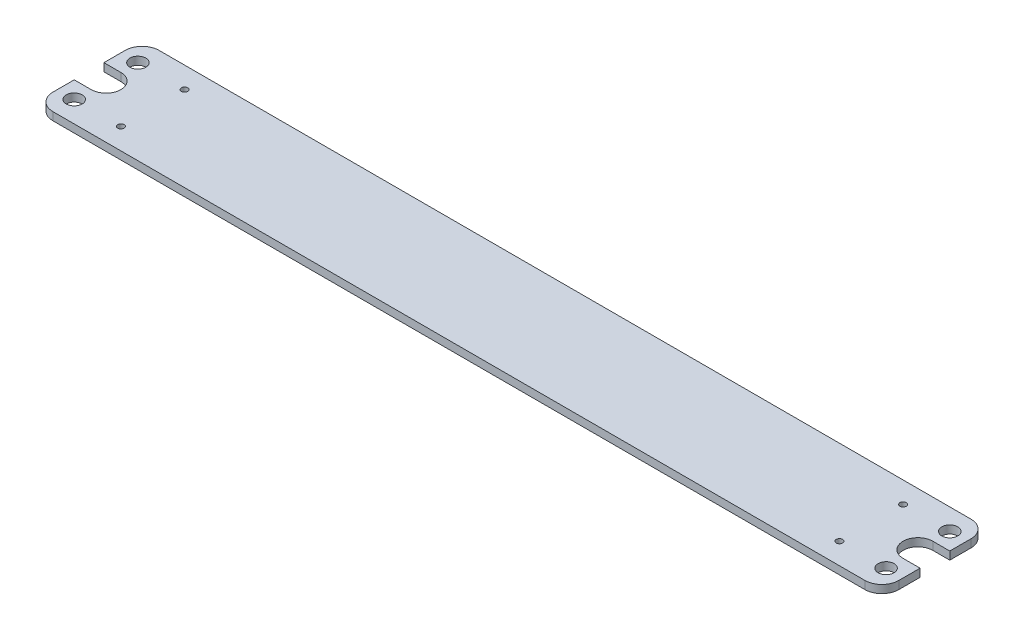
from build123d import *

# Parameters (mm, degrees)
SKETCH1_R           = 4.7625
SKETCH1_R_2         = 1.905
BOSS_EXTRUDE1_DEPTH = 4.7625


with BuildPart() as part:
    # Sketch1 → Boss-Extrude1 (new body)
    with BuildSketch(Plane(origin=(0, 0, 0), x_dir=(1, 0, 0), z_dir=(0, 1, 0))):
        with BuildLine():
            Line((10.16, 0), (253.0475, 0))
            Line((253.0475, 0), (253.0475, -63.5))
            Line((253.0475, -63.5), (10.16, -63.5))
            ThreePointArc((10.16, -63.5), (2.975795103, -60.524204897), (0, -53.34))
            Line((0, -53.34), (0, -40.64))
            Line((0, -40.64), (10.16, -40.64))
            ThreePointArc((10.16, -40.64), (19.05, -31.75), (10.16, -22.86))
            Line((10.16, -22.86), (0, -22.86))
            Line((0, -22.86), (0, -10.16))
            ThreePointArc((0, -10.16), (2.975795103, -2.975795103), (10.16, 0))
        make_face()
        with Locations((10.16, -50.8)):
            Circle(SKETCH1_R, mode=Mode.SUBTRACT)
        with Locations((10.16, -12.7)):
            Circle(SKETCH1_R, mode=Mode.SUBTRACT)
        with Locations((38.1, -50.8)):
            Circle(SKETCH1_R_2, mode=Mode.SUBTRACT)
        with Locations((38.1, -12.7)):
            Circle(SKETCH1_R_2, mode=Mode.SUBTRACT)
    boss_extrude1 = extrude(amount=BOSS_EXTRUDE1_DEPTH)

    # Mirror1: Boss-Extrude1 across plane
    add(boss_extrude1.mirror(Plane(origin=(253.0475, 4.7625, 63.5), x_dir=(0, 0, 1), z_dir=(-1, 0, 0))))


solid = part.part
